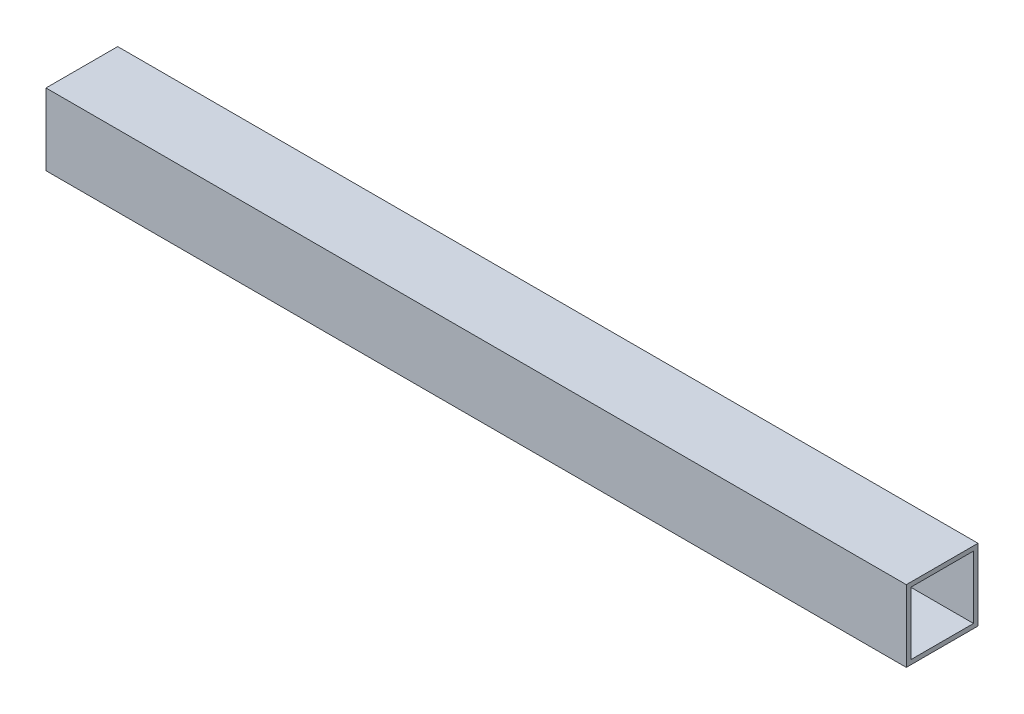
from build123d import *

# Parameters (mm, degrees)
SKETCH2_W           = 25.4
SKETCH2_H           = 25.4
SKETCH2_W_2         = 22.225
SKETCH2_H_2         = 22.225
EXTRUDE_THIN1_DEPTH = 304.8


with BuildPart() as part:
    # Sketch2 → Extrude-Thin1 (new body)
    with BuildSketch(Plane(origin=(0, 0, 0), x_dir=(0, 0, -1), z_dir=(1, 0, 0))):
        Rectangle(SKETCH2_W, SKETCH2_H)
        Rectangle(SKETCH2_W_2, SKETCH2_H_2, mode=Mode.SUBTRACT)
    extrude(amount=EXTRUDE_THIN1_DEPTH)


solid = part.part
